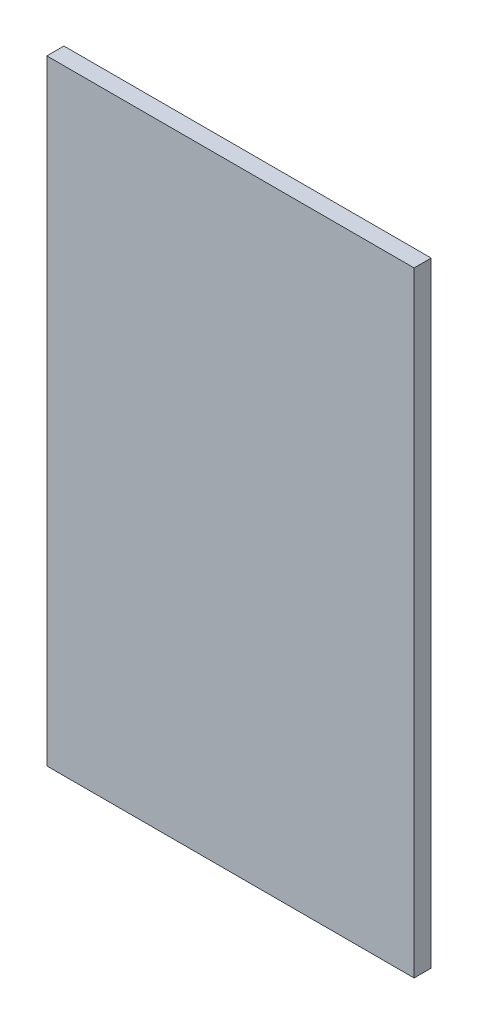
from build123d import *

# Parameters (mm, degrees)
BOSS_EXTRUDE1_DEPTH      = 114.3
BOSS_EXTRUDE1_DEPTH_BACK = 114.3
SKETCH1_W                = 136.525
SKETCH1_H                = 6.35


with BuildPart() as part:
    # Sketch1 → Boss-Extrude1 (new, two sides: drawn at the far end of the back side and taken through both)
    with BuildSketch(Plane(origin=(0, 0, 0), x_dir=(1, 0, 0), z_dir=(0, 1, 0)).offset(-BOSS_EXTRUDE1_DEPTH_BACK)):
        with Locations((-3.175, -2.38125)):
            Rectangle(SKETCH1_W, SKETCH1_H)
    extrude(amount=BOSS_EXTRUDE1_DEPTH + BOSS_EXTRUDE1_DEPTH_BACK)


solid = part.part
